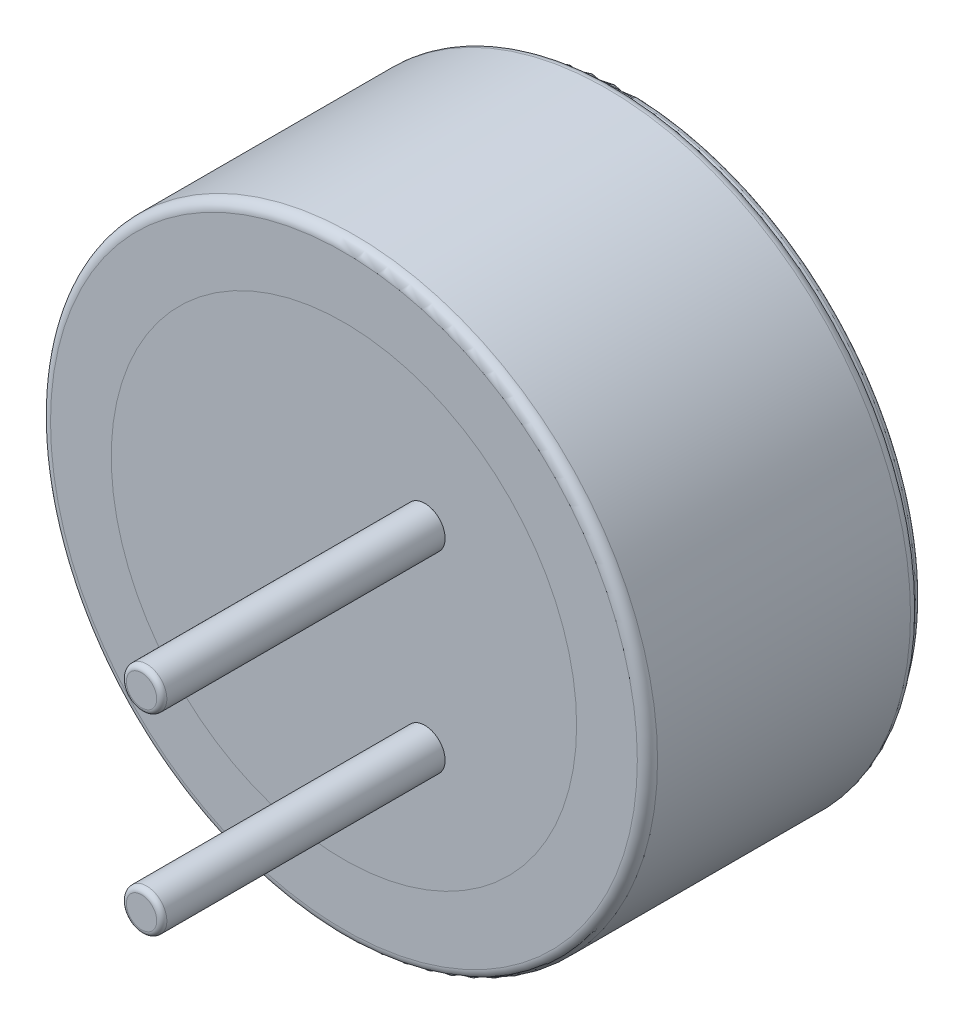
from build123d import *

# Parameters (mm, degrees)
SKETCH1_R             = 3
BOSS_EXTRUDE1_DEPTH   = 2.7
SKETCH3_R             = 0.2
BOSS_EXTRUDE2_DEPTH   = 2.8
BOSS_EXTRUDE2_2_DEPTH = 2.8
FILLET1_R             = 0.1
SKETCH4_R             = 2.9
BOSS_EXTRUDE3_DEPTH   = 0.1
FILLET2_R             = 0.05
SKETCH6_R             = 2.3
CUT_EXTRUDE1_DEPTH    = 0.1
SKETCH7_R             = 2.3
BOSS_EXTRUDE6_DEPTH   = 0.1
FILLET3_R             = 0.05
FILLET4_R             = 0.05


with BuildPart() as part:
    # Sketch1 → Boss-Extrude1 (new body)
    with BuildSketch(Plane.XY):
        Circle(SKETCH1_R)
    extrude(amount=BOSS_EXTRUDE1_DEPTH)

    # Fillet1
    fillet1_edges = [part.edges().sort_by_distance(p)[0] for p in [
        (-3, 0, 0),
        (-3, 0, 2.7),
    ]]
    fillet(fillet1_edges, radius=FILLET1_R)

    # Sketch6 → Cut-Extrude1 (cut)
    with BuildSketch(Plane.XY.offset(2.7)):
        Circle(SKETCH6_R)
    extrude(amount=-CUT_EXTRUDE1_DEPTH, mode=Mode.SUBTRACT)


with BuildPart() as body_2:
    # Sketch3 → Boss-Extrude2 (new body)
    with BuildSketch(Plane.XY.offset(2.7)):
        with Locations((0.8, -0.95)):
            Circle(SKETCH3_R)
    extrude(amount=BOSS_EXTRUDE2_DEPTH)

    # Fillet3
    fillet3_edges = [body_2.edges().sort_by_distance(p)[0] for p in [
        (0.6, -0.95, 5.5),
    ]]
    fillet(fillet3_edges, radius=FILLET3_R)


with BuildPart() as body_3:
    # Sketch3 → Boss-Extrude2 2 (new body)
    with BuildSketch(Plane.XY.offset(2.7)):
        with Locations((0.8, 0.95)):
            Circle(SKETCH3_R)
    extrude(amount=BOSS_EXTRUDE2_2_DEPTH)

    # Fillet4
    fillet4_edges = [body_3.edges().sort_by_distance(p)[0] for p in [
        (0.6, 0.95, 5.5),
    ]]
    fillet(fillet4_edges, radius=FILLET4_R)


with BuildPart() as body_4:
    # Sketch4 → Boss-Extrude3 (new body)
    with BuildSketch(Plane(origin=(0, 0, 0), x_dir=(-1, 0, 0), z_dir=(0, 0, -1))):
        Circle(SKETCH4_R)
    extrude(amount=BOSS_EXTRUDE3_DEPTH)

    # Fillet2
    fillet2_edges = [body_4.edges().sort_by_distance(p)[0] for p in [
        (2.9, 0, -0.1),
    ]]
    fillet(fillet2_edges, radius=FILLET2_R)


with BuildPart() as body_5:
    # Sketch7 → Boss-Extrude6 (new body)
    with BuildSketch(Plane.XY.offset(2.6)):
        Circle(SKETCH7_R)
    extrude(amount=BOSS_EXTRUDE6_DEPTH)


solid = Compound([part.part, body_2.part, body_3.part, body_4.part, body_5.part])
